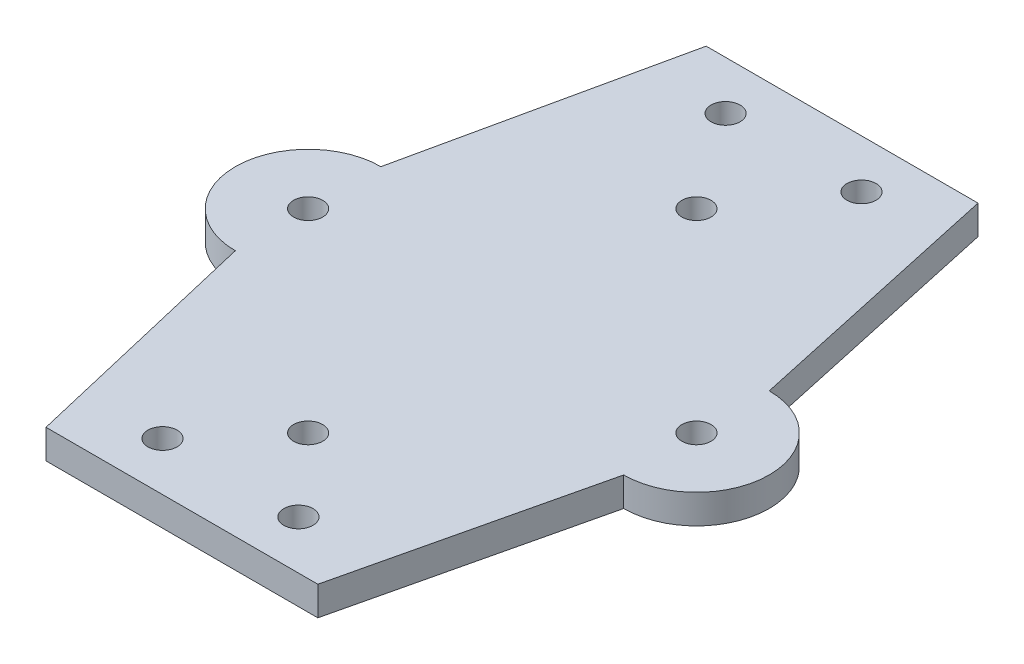
from build123d import *

# Parameters (mm, degrees)
BOSS_EXTRUDE1_DEPTH      = 1.5
BOSS_EXTRUDE1_DEPTH_BACK = 1.5
SKETCH1_R                = 1.5


with BuildPart() as part:
    # Sketch1 → Boss-Extrude1 (new, two sides: drawn at the far end of the back side and taken through both)
    with BuildSketch(Plane(origin=(0, 0, 0), x_dir=(1, 0, 0), z_dir=(0, 1, 0)).offset(-BOSS_EXTRUDE1_DEPTH_BACK)):
        with BuildLine():
            Line((-14, 35), (-20, 7.5))
            ThreePointArc((-20, 7.5), (-27.5, 0), (-20, -7.5))
            Line((-20, -7.5), (-14, -33))
            Line((-14, -33), (14, -33))
            Line((14, -33), (20, -7.5))
            ThreePointArc((20, -7.5), (27.5, 0), (20, 7.5))
            Line((20, 7.5), (14, 35))
            Line((14, 35), (-14, 35))
        make_face()
        with Locations((0, 20)):
            Circle(SKETCH1_R, mode=Mode.SUBTRACT)
        with Locations((0, -20)):
            Circle(SKETCH1_R, mode=Mode.SUBTRACT)
        with Locations((-7, -28)):
            Circle(SKETCH1_R, mode=Mode.SUBTRACT)
        with Locations((-7, 30)):
            Circle(SKETCH1_R, mode=Mode.SUBTRACT)
        with Locations((7, 30)):
            Circle(SKETCH1_R, mode=Mode.SUBTRACT)
        with Locations((7, -28)):
            Circle(SKETCH1_R, mode=Mode.SUBTRACT)
        with Locations((-20, 0)):
            Circle(SKETCH1_R, mode=Mode.SUBTRACT)
        with Locations((20, 0)):
            Circle(SKETCH1_R, mode=Mode.SUBTRACT)
    extrude(amount=BOSS_EXTRUDE1_DEPTH + BOSS_EXTRUDE1_DEPTH_BACK)


solid = part.part
